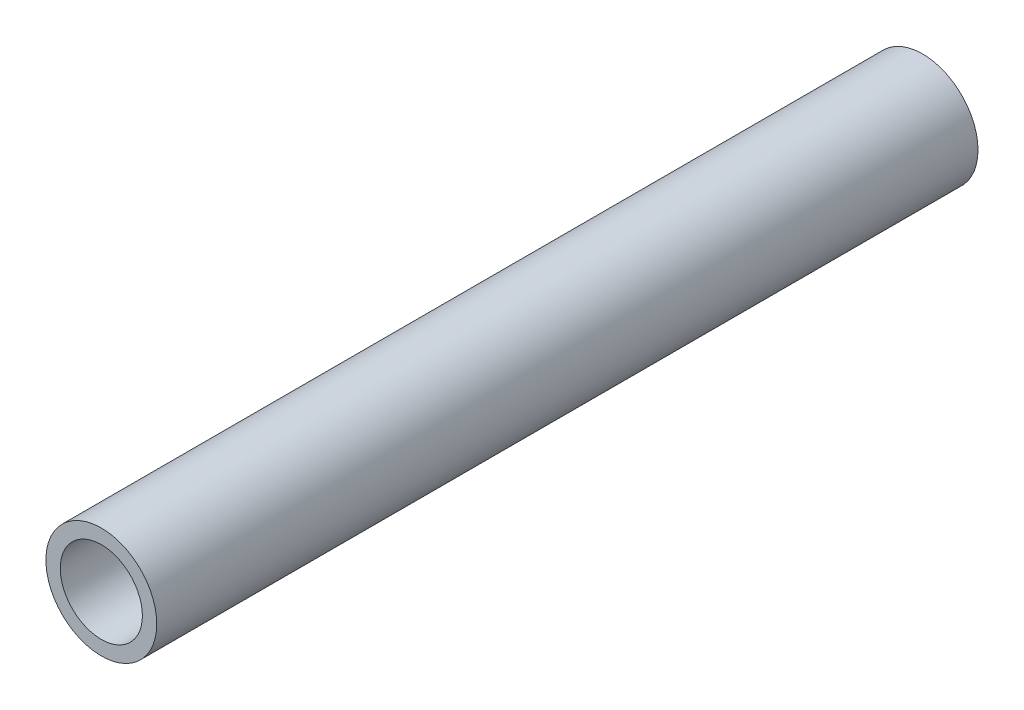
from build123d import *

# Parameters (mm, degrees)
SKETCH1_R           = 1.35
SKETCH1_R_2         = 1
BOSS_EXTRUDE1_DEPTH = 20


with BuildPart() as part:
    # Sketch1 → Boss-Extrude1 (new body)
    with BuildSketch(Plane.XY):
        Circle(SKETCH1_R)
        Circle(SKETCH1_R_2, mode=Mode.SUBTRACT)
    extrude(amount=BOSS_EXTRUDE1_DEPTH)


solid = part.part
